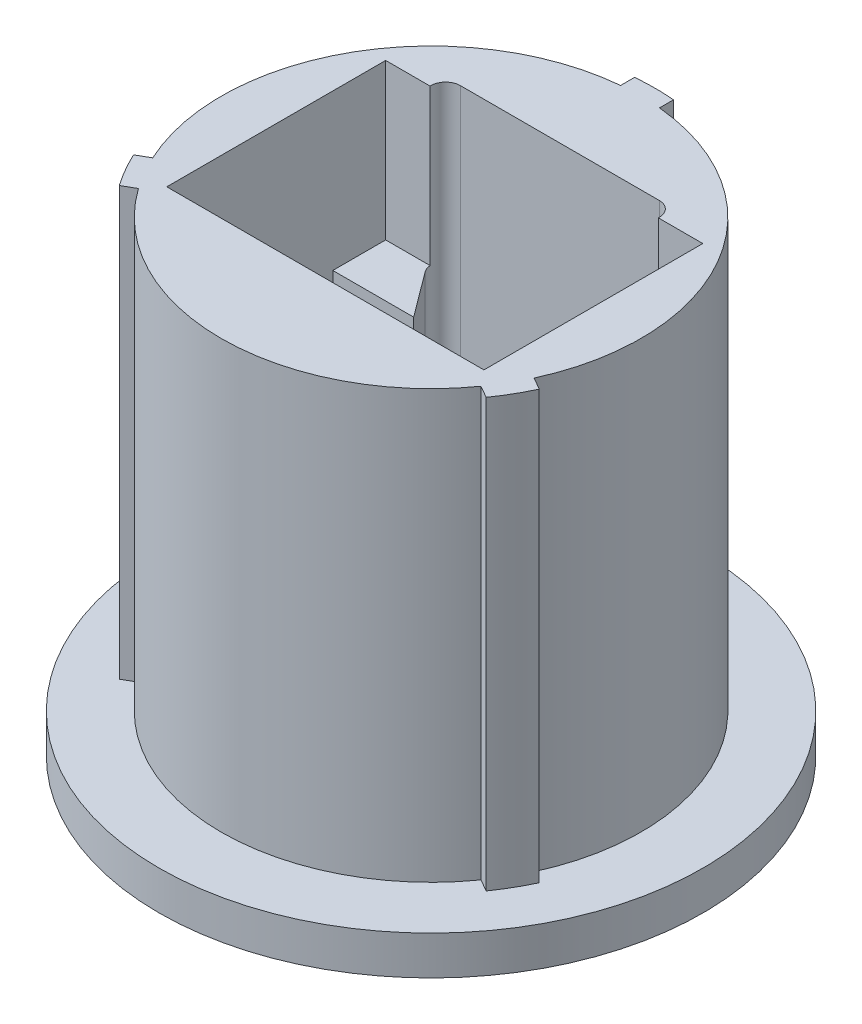
from build123d import *

# Parameters (mm, degrees)
BOSS_EXTRUDE1_DEPTH     = 19.05
CUT_EXTRUDE1_DEPTH      = 23.803574111
CUT_EXTRUDE2_DEPTH      = 18.25625
SKETCH6_W               = 0.608326788
SKETCH6_H               = 1.5875
SKETCH8_W               = 2.576826788
SKETCH8_H               = 1.5875
SKETCH9_W               = 12.954
SKETCH9_H               = 5.08
SKETCH9_H_2             = 2.159
CUT_EXTRUDE3_DEPTH      = 6.35
CUT_EXTRUDE5_DEPTH      = 25.695704333
CUT_EXTRUDE5_DEPTH_BACK = 25.695704333
SKETCH11_W              = 3.175
SKETCH11_H              = 5.08
SKETCH10_R              = 1.016
CUT_EXTRUDE6_DEPTH      = 26.047832371


with BuildPart() as part:
    # Sketch1 → Boss-Extrude1 (new body)
    with BuildSketch(Plane(origin=(0, 0, 0), x_dir=(1, 0, 0), z_dir=(0, 1, 0))):
        with BuildLine():
            Line((-0.79375, 9.109483901), (-0.79375, 8.535673212))
            ThreePointArc((-0.79375, 8.535673212), (-7.424002774, 4.28625), (-7.78898484, -3.580428942))
            Line((-7.78898484, -3.580428942), (-8.285919473, -3.867334286))
            ThreePointArc((-8.285919473, -3.867334286), (-7.918936292, -4.572), (-7.492169473, -5.242149615))
            Line((-7.492169473, -5.242149615), (-6.99523484, -4.95524427))
            ThreePointArc((-6.99523484, -4.95524427), (0, -8.5725), (6.99523484, -4.95524427))
            Line((6.99523484, -4.95524427), (7.492169473, -5.242149615))
            ThreePointArc((7.492169473, -5.242149615), (7.918936292, -4.572), (8.285919473, -3.867334286))
            Line((8.285919473, -3.867334286), (7.78898484, -3.580428942))
            ThreePointArc((7.78898484, -3.580428942), (7.424002774, 4.28625), (0.79375, 8.535673212))
            Line((0.79375, 8.535673212), (0.79375, 9.109483901))
            ThreePointArc((0.79375, 9.109483901), (0, 9.144), (-0.79375, 9.109483901))
        make_face()
    extrude(amount=BOSS_EXTRUDE1_DEPTH)

    # Sketch2 → Cut-Extrude1 (cut, through all)
    with BuildSketch(Plane(origin=(0, 19.05, 0), x_dir=(1, 0, 0), z_dir=(0, 1, 0))):
        with BuildLine():
            Line((-4.543615348, 4.303093955), (-3.175, 2.4638))
            Line((-3.175, 2.4638), (3.175, 2.4638))
            Line((3.175, 2.4638), (4.543615348, 4.303093955))
            ThreePointArc((4.543615348, 4.303093955), (4.598203733, 4.928342625), (4.064, 5.2578))
            Line((4.064, 5.2578), (-4.064, 5.2578))
            ThreePointArc((-4.064, 5.2578), (-4.598203733, 4.928342625), (-4.543615348, 4.303093955))
        make_face()
    extrude(amount=-CUT_EXTRUDE1_DEPTH, mode=Mode.SUBTRACT)

    # Sketch2_4 → Cut-Extrude2 (cut)
    with BuildSketch(Plane(origin=(0, 19.05, 0), x_dir=(1, 0, 0), z_dir=(0, 1, 0))):
        Polygon((3.175, 2.4638), (-3.175, 2.4638), (-6.477, 2.4638), (-6.477, 0.762), (6.477, 0.762), (6.477, 2.4638), align=None)
    extrude(amount=-CUT_EXTRUDE2_DEPTH, mode=Mode.SUBTRACT)

    # Sketch6 → Cut-Revolve2 (revolve, cut)
    with BuildSketch(Plane(origin=(0, 0, 0), x_dir=(0, 0, -1), z_dir=(1, 0, 0))):
        with Locations((8.839836606, 0.79375)):
            Rectangle(SKETCH6_W, SKETCH6_H)
    revolve(axis=Axis((0, 19.730213777, 0), (0, -1, 0)), mode=Mode.SUBTRACT)

    # Sketch8 → Revolve2 (revolve)
    with BuildSketch(Plane(origin=(0, 0, 0), x_dir=(0, 0, -1), z_dir=(1, 0, 0))):
        with Locations((9.824086606, 0.79375)):
            Rectangle(SKETCH8_W, SKETCH8_H)
    revolve(axis=Axis((0, 4.48386458, 0), (0, -1, 0)))

    # Sketch9 → Cut-Extrude3 (cut)
    with BuildSketch(Plane(origin=(0, 19.05, 0), x_dir=(1, 0, 0), z_dir=(0, 1, 0))):
        with Locations((0, -1.778)):
            Rectangle(SKETCH9_W, SKETCH9_H)
        with Locations((0, 3.5433)):
            Rectangle(SKETCH9_W, SKETCH9_H_2)
    extrude(amount=-CUT_EXTRUDE3_DEPTH, mode=Mode.SUBTRACT)

    # Sketch11 → Cut-Extrude5 (cut, two sides: drawn at the far end of the back side and taken through both)
    with BuildSketch(Plane(origin=(0, 0, 0), x_dir=(0, 0, -1), z_dir=(1, 0, 0)).offset(-CUT_EXTRUDE5_DEPTH_BACK)):
        with Locations((7.5565, 7.77875)):
            Rectangle(SKETCH11_W, SKETCH11_H)
    extrude(amount=CUT_EXTRUDE5_DEPTH + CUT_EXTRUDE5_DEPTH_BACK, mode=Mode.SUBTRACT)

    # Sketch10 → Cut-Extrude6 (cut, through all)
    with BuildSketch(Plane(origin=(0, 0, -0.762), x_dir=(-1, 0, 0), z_dir=(0, 0, -1))):
        with Locations((-4.572, 7.39775)):
            Circle(SKETCH10_R)
        with Locations((4.445, 7.39775)):
            Circle(SKETCH10_R)
    extrude(amount=CUT_EXTRUDE6_DEPTH, mode=Mode.SUBTRACT)


solid = part.part
